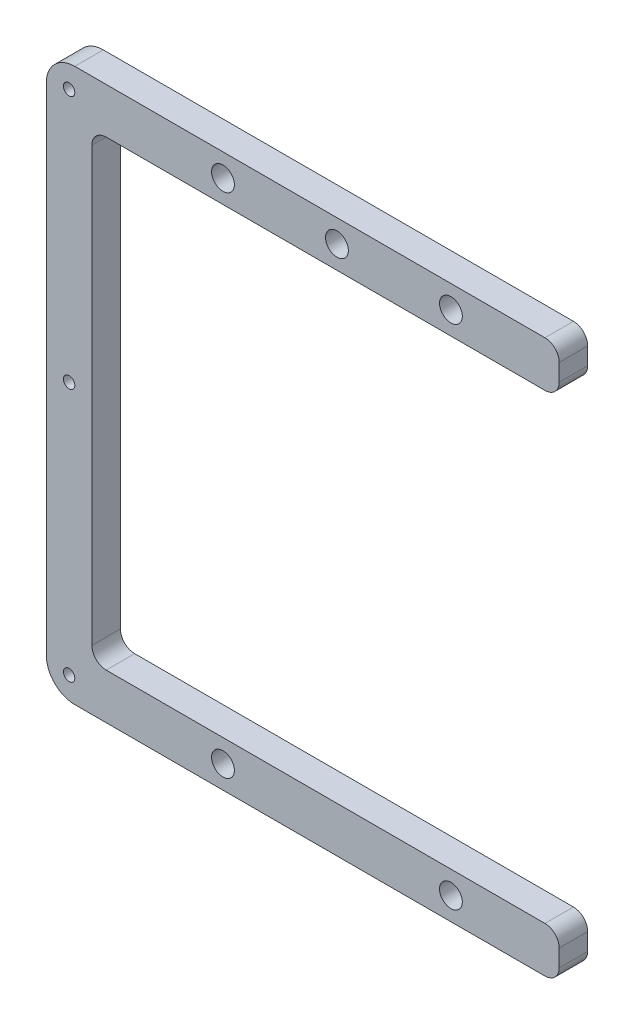
from build123d import *

# Parameters (mm, degrees)
BOSS_EXTRUDE1_DEPTH = 5
SKETCH4_R           = 2
CUT_EXTRUDE1_DEPTH  = 6
SKETCH5_R           = 1
CUT_EXTRUDE2_DEPTH  = 3


with BuildPart() as part:
    # Sketch1 → Boss-Extrude1 (new body)
    with BuildSketch(Plane.XY):
        with BuildLine():
            Line((0, -43.5), (0, 43.5))
            ThreePointArc((0, 43.5), (1.464466094, 47.035533906), (5, 48.5))
            Line((5, 48.5), (87.5, 48.5))
            ThreePointArc((87.5, 48.5), (89.267766953, 47.767766953), (90, 46))
            Line((90, 46), (90, 43))
            ThreePointArc((90, 43), (89.267766953, 41.232233047), (87.5, 40.5))
            Line((87.5, 40.5), (10.5, 40.5))
            ThreePointArc((10.5, 40.5), (8.732233047, 39.767766953), (8, 38))
            Line((8, 38), (8, -38))
            ThreePointArc((8, -38), (8.732233047, -39.767766953), (10.5, -40.5))
            Line((10.5, -40.5), (87.5, -40.5))
            ThreePointArc((87.5, -40.5), (89.267766953, -41.232233047), (90, -43))
            Line((90, -43), (90, -46))
            ThreePointArc((90, -46), (89.267766953, -47.767766953), (87.5, -48.5))
            Line((87.5, -48.5), (5, -48.5))
            ThreePointArc((5, -48.5), (1.464466094, -47.035533906), (0, -43.5))
        make_face()
    extrude(amount=BOSS_EXTRUDE1_DEPTH)

    # Sketch4 → Cut-Extrude1 (cut, through all)
    with BuildSketch(Plane.XY.offset(5)):
        with Locations((71, 44.5)):
            Circle(SKETCH4_R)
        with Locations((31, 44.5)):
            Circle(SKETCH4_R)
        with Locations((71, -44.5)):
            Circle(SKETCH4_R)
        with Locations((31, -44.5)):
            Circle(SKETCH4_R)
        with Locations((51, 44.5)):
            Circle(SKETCH4_R)
    extrude(amount=-CUT_EXTRUDE1_DEPTH, mode=Mode.SUBTRACT)

    # Sketch5 → Cut-Extrude2 (cut)
    with BuildSketch(Plane.XY.offset(5)):
        with Locations((4, 44.5)):
            Circle(SKETCH5_R)
        with Locations((4, 0)):
            Circle(SKETCH5_R)
        with Locations((4, -44.5)):
            Circle(SKETCH5_R)
    extrude(amount=-CUT_EXTRUDE2_DEPTH, mode=Mode.SUBTRACT)


solid = part.part
